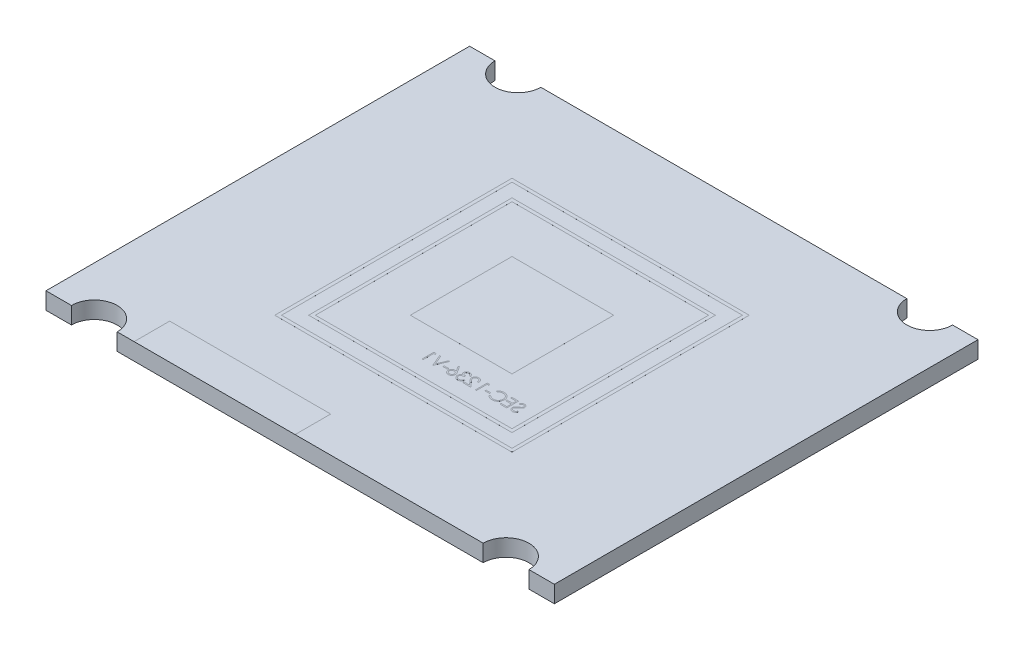
from build123d import *

# Parameters (mm, degrees)
SKETCH1_W               = 30
SKETCH1_H               = 25
BOSS_EXTRUDE1_DEPTH     = 0.5
SKETCH3_R               = 1.35
CUT_EXTRUDE2_DEPTH      = 1.5
CUT_EXTRUDE2_DEPTH_BACK = 1.5
SKETCH2_W               = 6
SKETCH2_H               = 6
BOSS_EXTRUDE2_DEPTH     = 0.50005
SKETCH4_R               = 2.25
BOSS_EXTRUDE3_DEPTH     = 2
SKETCH5_R               = 0.5
CUT_EXTRUDE3_DEPTH      = 0.4
REVOLVE1_ANGLE          = 180
CHAMFER1_SIZE           = 0.2
SKETCH9_W               = 9.5
SKETCH9_H               = 2.1
MARCA_O_FIOS_DEPTH      = 0.50005
SKETCH10_W              = 14
SKETCH10_H              = 14
SKETCH10_W_2            = 13.6
SKETCH10_H_2            = 13.6
SKETCH10_W_3            = 12
SKETCH10_H_3            = 12
SKETCH10_W_4            = 11.6
SKETCH10_H_4            = 11.6
CONTORNO_C_MERA_DEPTH   = 0.5005
SKETCH11_W              = 0.26923077
SKETCH11_H              = 0.071794871
BOSS_EXTRUDE6_DEPTH     = 0.5005


with BuildPart() as part:
    # Sketch1 → Boss-Extrude1 (new body, symmetric)
    with BuildSketch(Plane(origin=(0, 0, 0), x_dir=(1, 0, 0), z_dir=(0, 1, 0))):
        Rectangle(SKETCH1_W, SKETCH1_H)
    extrude(amount=BOSS_EXTRUDE1_DEPTH, both=True)

    # Sketch3 → Cut-Extrude2 (cut, two sides)
    with BuildSketch(Plane(origin=(0, 0, 0), x_dir=(1, 0, 0), z_dir=(0, 1, 0))) as cut_extrude2_sk:
        with Locations((-12.15, 12.5)):
            Circle(SKETCH3_R)
        with Locations((12.15, 12.5)):
            Circle(SKETCH3_R)
        with Locations((12.15, -12.5)):
            Circle(SKETCH3_R)
        with Locations((-12.15, -12.5)):
            Circle(SKETCH3_R)
    extrude(amount=CUT_EXTRUDE2_DEPTH, mode=Mode.SUBTRACT)
    extrude(cut_extrude2_sk.sketch, amount=-CUT_EXTRUDE2_DEPTH_BACK, mode=Mode.SUBTRACT)

    # Sketch2 → Boss-Extrude2 (add, symmetric)
    with BuildSketch(Plane(origin=(0, 0, 0), x_dir=(1, 0, 0), z_dir=(0, 1, 0))):
        Rectangle(SKETCH2_W, SKETCH2_H)
    extrude(amount=BOSS_EXTRUDE2_DEPTH, both=True)

    # Sketch4 → Boss-Extrude3 (add)
    with BuildSketch(Plane.XZ.offset(0.50005)):
        Circle(SKETCH4_R)
    extrude(amount=BOSS_EXTRUDE3_DEPTH)

    # Sketch5 → Cut-Extrude3 (cut)
    with BuildSketch(Plane.XZ.offset(2.50005)):
        Circle(SKETCH5_R)
    extrude(amount=-CUT_EXTRUDE3_DEPTH, mode=Mode.SUBTRACT)

    # Sketch6 → Revolve1 (revolve)
    with BuildSketch(Plane.XZ.offset(2.10005)):
        with BuildLine():
            Line((-0.5, 0), (0.5, 0))
            ThreePointArc((0.5, 0), (0, 0.5), (-0.5, 0))
        make_face()
    revolve(axis=Axis((-0.5, -2.10005, 0), (1, 0, 0)), revolution_arc=REVOLVE1_ANGLE)

    # Chamfer1
    chamfer1_edges = [part.edges().sort_by_distance(p)[0] for p in [
        (-2.25, -0.50005, 0),
        (-2.25, -2.50005, 0),
        (-0.5, -2.50005, 0),
    ]]
    chamfer(chamfer1_edges, length=CHAMFER1_SIZE)

    # Sketch9 → Marcação Fios (add, symmetric)
    with BuildSketch(Plane(origin=(0, 0, 0), x_dir=(1, 0, 0), z_dir=(0, 1, 0))):
        with Locations((-5.05, -11.45)):
            Rectangle(SKETCH9_W, SKETCH9_H)
    extrude(amount=MARCA_O_FIOS_DEPTH, both=True)

    # Sketch10 → Contorno Câmera (add, symmetric)
    with BuildSketch(Plane(origin=(0, 0, 0), x_dir=(1, 0, 0), z_dir=(0, 1, 0))):
        Rectangle(SKETCH10_W, SKETCH10_H)
        Rectangle(SKETCH10_W_2, SKETCH10_H_2, mode=Mode.SUBTRACT)
        Rectangle(SKETCH10_W_3, SKETCH10_H_3)
        Rectangle(SKETCH10_W_4, SKETCH10_H_4, mode=Mode.SUBTRACT)
    extrude(amount=CONTORNO_C_MERA_DEPTH, both=True)

    # Sketch11 → Boss-Extrude6 (add, symmetric)
    with BuildSketch(Plane(origin=(0, 0, 0), x_dir=(1, 0, 0), z_dir=(0, 1, 0))):
        with BuildLine():
            Line((5.140170855, -4.761384611), (5.080996176, -4.725907848))
            add(Edge.make_bspline(
                [(5.080996176, -4.725907848), (5.075492528, -4.735120725), (5.064947752, -4.752772242), (5.04735748, -4.77662385), (5.029130898, -4.796896281), (5.010133032, -4.813471603), (4.990479842, -4.82652138), (4.970043031, -4.835761827), (4.948891469, -4.841525022), (4.934496705, -4.842225039), (4.927310278, -4.842574515)],
                knots=[0, 0, 0, 0, 3.218e-05, 6.1656e-05, 8.8756e-05, 0.000113806, 0.000137103, 0.000159257, 0.000180854, 0.000202386, 0.000202386, 0.000202386, 0.000202386], degree=3))
            add(Edge.make_bspline(
                [(4.927310278, -4.842574515), (4.921172906, -4.84240358), (4.909005552, -4.842064702), (4.891093103, -4.838808542), (4.873696743, -4.833806116), (4.857175015, -4.82664193), (4.841755892, -4.817974233), (4.828234553, -4.807504997), (4.816545331, -4.795783756), (4.806983508, -4.782707225), (4.799647501, -4.768643795), (4.794009087, -4.754208605), (4.790880072, -4.739174891), (4.790408721, -4.729052799), (4.790170855, -4.723944707)],
                knots=[0, 0, 0, 0, 1.8396e-05, 3.6469e-05, 5.444e-05, 7.2595e-05, 9.037e-05, 0.000107367, 0.000123728, 0.000139883, 0.000155753, 0.000171197, 0.00018624, 0.000201566, 0.000201566, 0.000201566, 0.000201566], degree=3))
            add(Edge.make_bspline(
                [(4.790170855, -4.723944707), (4.790465718, -4.718116537), (4.791065129, -4.706268719), (4.796131425, -4.688788789), (4.804101275, -4.671490275), (4.811453803, -4.660790022), (4.815271016, -4.655234771)],
                knots=[0, 0, 0, 0, 1.7456e-05, 3.5486e-05, 5.4182e-05, 7.4369e-05, 7.4369e-05, 7.4369e-05, 7.4369e-05], degree=3))
            add(Edge.make_bspline(
                [(4.815271016, -4.655234771), (4.818405138, -4.651225407), (4.824984837, -4.642808247), (4.83629634, -4.6302792), (4.849569563, -4.617355516), (4.864350274, -4.603543705), (4.881176891, -4.589486145), (4.899522394, -4.57451249), (4.919855166, -4.559192174), (4.934115065, -4.548917661), (4.941472939, -4.543616182)],
                knots=[0, 0, 0, 0, 1.5264e-05, 3.2045e-05, 5.0587e-05, 7.0829e-05, 9.2716e-05, 0.000116346, 0.000141867, 0.000169074, 0.000169074, 0.000169074, 0.000169074], degree=3))
            add(Edge.make_bspline(
                [(4.941472939, -4.543616182), (4.948837738, -4.538370464), (4.962918673, -4.528341052), (4.98261039, -4.513456195), (5.000219282, -4.499847421), (5.015667086, -4.487386618), (5.028947005, -4.476072097), (5.040163687, -4.46601251), (5.049031399, -4.456935797), (5.053962515, -4.451047529), (5.056176464, -4.448403842)],
                knots=[0, 0, 0, 0, 2.7125e-05, 5.186e-05, 7.4047e-05, 9.3888e-05, 0.000111394, 0.000126382, 0.000139075, 0.000149418, 0.000149418, 0.000149418, 0.000149418], degree=3))
            add(Edge.make_bspline(
                [(5.056176464, -4.448403842), (5.059270973, -4.444283634), (5.065356741, -4.436180694), (5.073389942, -4.423515722), (5.080217774, -4.410551069), (5.085570241, -4.397251896), (5.090077485, -4.38380491), (5.093109071, -4.370034661), (5.09500735, -4.356002938), (5.095201747, -4.346560237), (5.095299061, -4.341833329)],
                knots=[0, 0, 0, 0, 1.5454e-05, 3.0392e-05, 4.4943e-05, 5.9343e-05, 7.3356e-05, 8.744e-05, 0.00010158, 0.000115754, 0.000115754, 0.000115754, 0.000115754], degree=3))
            add(Edge.make_bspline(
                [(5.095299061, -4.341833329), (5.095038019, -4.334427374), (5.094521515, -4.319773761), (5.090153411, -4.298367595), (5.083258833, -4.277930312), (5.073599855, -4.258664245), (5.061148384, -4.241071049), (5.046739189, -4.224948351), (5.029576892, -4.211394635), (5.010746368, -4.199552223), (4.990135093, -4.190283038), (4.968536912, -4.183290842), (4.945917498, -4.179328991), (4.930596871, -4.178760438), (4.922823099, -4.178471951)],
                knots=[0, 0, 0, 0, 2.22e-05, 4.3925e-05, 6.5254e-05, 8.6764e-05, 0.000108315, 0.000129755, 0.000151392, 0.000173688, 0.000196341, 0.000219002, 0.000241641, 0.00026496, 0.00026496, 0.00026496, 0.00026496], degree=3))
            add(Edge.make_bspline(
                [(4.922823099, -4.178471951), (4.914574279, -4.178756461), (4.898170009, -4.179322261), (4.874040165, -4.184241768), (4.850808022, -4.192381902), (4.832119369, -4.201619634), (4.817492817, -4.210845917), (4.80633827, -4.219249882), (4.79503478, -4.228924903), (4.783491169, -4.239896752), (4.771903037, -4.252266103), (4.760098347, -4.26594824), (4.748049493, -4.280859552), (4.740298321, -4.291504452), (4.736324702, -4.296961534)],
                knots=[0, 0, 0, 0, 2.4728e-05, 4.9175e-05, 7.3522e-05, 9.8418e-05, 0.000111528, 0.000125354, 0.000140274, 0.000156144, 0.000173106, 0.000191099, 0.000210349, 0.000230598, 0.000230598, 0.000230598, 0.000230598], degree=3))
            Line((4.736324702, -4.296961534), (4.793115567, -4.340010412))
            add(Edge.make_bspline(
                [(4.793115567, -4.340010412), (4.796544753, -4.335592674), (4.803148565, -4.327085144), (4.813174462, -4.31517088), (4.822624192, -4.304287585), (4.831934272, -4.294834559), (4.840612998, -4.286294132), (4.849036406, -4.278982181), (4.857083277, -4.272827062), (4.867226659, -4.26625835), (4.879970203, -4.259747049), (4.89596711, -4.254237233), (4.912684365, -4.250926221), (4.924070291, -4.250488444), (4.929834317, -4.250266823)],
                knots=[0, 0, 0, 0, 1.6775e-05, 3.2306e-05, 4.671e-05, 5.9999e-05, 7.2097e-05, 8.323e-05, 9.3439e-05, 0.000102462, 0.000119457, 0.00013622, 0.000153078, 0.000170362, 0.000170362, 0.000170362, 0.000170362], degree=3))
            add(Edge.make_bspline(
                [(4.929834317, -4.250266823), (4.937065621, -4.250509163), (4.951010511, -4.250976492), (4.970808558, -4.256080489), (4.988627343, -4.264116862), (5.003937856, -4.275379857), (5.016685252, -4.288724056), (5.025906343, -4.304079827), (5.031456376, -4.321036307), (5.032133632, -4.332864638), (5.032478548, -4.338888617)],
                knots=[0, 0, 0, 0, 2.165e-05, 4.1749e-05, 6.0886e-05, 7.9959e-05, 9.8411e-05, 0.000115894, 0.000133277, 0.000151318, 0.000151318, 0.000151318, 0.000151318], degree=3))
            add(Edge.make_bspline(
                [(5.032478548, -4.338888617), (5.032399922, -4.342638913), (5.032242543, -4.350145637), (5.030047584, -4.361235921), (5.027227718, -4.372298189), (5.022759191, -4.383282706), (5.016590131, -4.394381578), (5.008489096, -4.405785925), (4.998286433, -4.417596267), (4.990471031, -4.425277742), (4.986344734, -4.429333329)],
                knots=[0, 0, 0, 0, 1.1232e-05, 2.2482e-05, 3.3809e-05, 4.5449e-05, 5.7938e-05, 7.1827e-05, 8.734e-05, 0.000104693, 0.000104693, 0.000104693, 0.000104693], degree=3))
            add(Edge.make_bspline(
                [(4.986344734, -4.429333329), (4.984812459, -4.430700734), (4.981172126, -4.433949376), (4.974516941, -4.439267832), (4.965728381, -4.445828386), (4.955035941, -4.45394585), (4.942242468, -4.463362142), (4.927346557, -4.473956865), (4.910514251, -4.486073956), (4.898569867, -4.494545464), (4.892254189, -4.499024835)],
                knots=[0, 0, 0, 0, 6.16e-06, 1.4635e-05, 2.5545e-05, 3.9063e-05, 5.4909e-05, 7.3198e-05, 9.39e-05, 0.000117129, 0.000117129, 0.000117129, 0.000117129], degree=3))
            add(Edge.make_bspline(
                [(4.892254189, -4.499024835), (4.884657006, -4.504553107), (4.869946115, -4.51525784), (4.849014599, -4.531340976), (4.830035837, -4.547070529), (4.812943196, -4.562346051), (4.797567815, -4.577051669), (4.784080271, -4.591364305), (4.772343135, -4.60518142), (4.759707291, -4.622895935), (4.746795727, -4.644652152), (4.735707425, -4.6713078), (4.728715756, -4.698067064), (4.727801453, -4.716052431), (4.727350343, -4.724926278)],
                knots=[0, 0, 0, 0, 2.8186e-05, 5.4579e-05, 7.9176e-05, 0.000102117, 0.000123339, 0.000142981, 0.000161096, 0.000177674, 0.000208218, 0.000236759, 0.000264068, 0.000290665, 0.000290665, 0.000290665, 0.000290665], degree=3))
            add(Edge.make_bspline(
                [(4.727350343, -4.724926278), (4.72748177, -4.731201951), (4.727742073, -4.743631427), (4.730734256, -4.761882443), (4.735118189, -4.779608617), (4.741725636, -4.796590839), (4.749790267, -4.813139792), (4.760023517, -4.828821372), (4.771885054, -4.843982652), (4.785491807, -4.85821935), (4.800380987, -4.871288589), (4.816117726, -4.882914401), (4.832727781, -4.892608066), (4.850121044, -4.900518234), (4.868301512, -4.906704938), (4.887263068, -4.911187512), (4.907036971, -4.913938654), (4.920477067, -4.914224206), (4.927310278, -4.914369387)],
                knots=[0, 0, 0, 0, 1.8809e-05, 3.7253e-05, 5.5346e-05, 7.3498e-05, 9.1809e-05, 0.00011048, 0.000129555, 0.000149491, 0.000169462, 0.000188927, 0.000208094, 0.000227045, 0.000246158, 0.000265613, 0.000285424, 0.000305914, 0.000305914, 0.000305914, 0.000305914], degree=3))
            add(Edge.make_bspline(
                [(4.927310278, -4.914369387), (4.932597347, -4.91426715), (4.943104899, -4.914063965), (4.958646795, -4.912267709), (4.973874713, -4.909726288), (4.98859757, -4.905691474), (5.003005052, -4.900796079), (5.017034499, -4.894768413), (5.03069271, -4.887544972), (5.044056226, -4.879285967), (5.057091061, -4.869674418), (5.069674955, -4.858479719), (5.082220792, -4.846010618), (5.094358271, -4.831928505), (5.1063329, -4.816460889), (5.117908582, -4.799463052), (5.129324925, -4.781027581), (5.136488019, -4.768054564), (5.140170855, -4.761384611)],
                knots=[0, 0, 0, 0, 1.5855e-05, 3.1511e-05, 4.6888e-05, 6.2126e-05, 7.7247e-05, 9.2511e-05, 0.000107878, 0.00012356, 0.000139602, 0.000156394, 0.000174043, 0.00019263, 0.000212123, 0.000232698, 0.000254296, 0.00027715, 0.00027715, 0.00027715, 0.00027715], degree=3))
        make_face()
        Polygon((4.583760599, -4.196420669), (4.188888804, -4.196420669), (4.188888804, -4.268215541), (4.520940086, -4.268215541), (4.520940086, -4.483600156), (4.188888804, -4.483600156), (4.188888804, -4.555395028), (4.520940086, -4.555395028), (4.520940086, -4.824625797), (4.188888804, -4.824625797), (4.188888804, -4.896420669), (4.583760599, -4.896420669), align=None)
        with BuildLine():
            Line((3.417093932, -4.324866182), (3.472061881, -4.366933489))
            add(Edge.make_bspline(
                [(3.472061881, -4.366933489), (3.475983059, -4.362260295), (3.483772548, -4.352976912), (3.496304389, -4.339941003), (3.509364717, -4.327727951), (3.522948541, -4.316279575), (3.537300365, -4.305996222), (3.552072525, -4.296342001), (3.567512134, -4.287688454), (3.588862481, -4.277195856), (3.616792051, -4.266246625), (3.651951018, -4.257065979), (3.688653238, -4.251221744), (3.713692758, -4.250588776), (3.726428868, -4.250266823)],
                knots=[0, 0, 0, 0, 1.8297e-05, 3.6347e-05, 5.4205e-05, 7.1925e-05, 8.9596e-05, 0.000107137, 0.000124843, 0.000142654, 0.000178484, 0.000214606, 0.000251493, 0.000289678, 0.000289678, 0.000289678, 0.000289678], degree=3))
            add(Edge.make_bspline(
                [(3.726428868, -4.250266823), (3.733445528, -4.250347615), (3.747413727, -4.25050845), (3.768143421, -4.252630275), (3.788486032, -4.255612517), (3.808428325, -4.260037582), (3.827944916, -4.265632106), (3.847163397, -4.272317189), (3.865805517, -4.280588156), (3.884129164, -4.289729808), (3.901685007, -4.300055297), (3.918296016, -4.311317968), (3.93390161, -4.323391787), (3.948514132, -4.336322008), (3.962148522, -4.3500504), (3.974705984, -4.364723269), (3.986143066, -4.380293703), (3.996686471, -4.396556385), (4.006129018, -4.413463943), (4.014034994, -4.431078957), (4.021036018, -4.449099778), (4.026575867, -4.46773001), (4.03096077, -4.486838563), (4.033986303, -4.506476721), (4.036083997, -4.526603457), (4.036244032, -4.540245319), (4.036324702, -4.547121791)],
                knots=[0, 0, 0, 0, 2.1041e-05, 4.1887e-05, 6.2452e-05, 8.2696e-05, 0.000103113, 0.000123336, 0.000143683, 0.000164252, 0.000184742, 0.000204732, 0.000224422, 0.000243893, 0.000263228, 0.000282422, 0.000301774, 0.000321144, 0.000340538, 0.000359803, 0.000379021, 0.000398496, 0.000418056, 0.00043779, 0.000458077, 0.000478698, 0.000478698, 0.000478698, 0.000478698], degree=3))
            add(Edge.make_bspline(
                [(4.036324702, -4.547121791), (4.036072338, -4.557468054), (4.035576855, -4.577781571), (4.031167188, -4.607535694), (4.02446617, -4.636039828), (4.014423054, -4.663115797), (4.002039244, -4.689097468), (3.986391122, -4.713545239), (3.968267815, -4.736828552), (3.947412931, -4.758397142), (3.924531767, -4.778099887), (3.899982185, -4.795450003), (3.873825328, -4.809912979), (3.846350002, -4.821948169), (3.817344779, -4.831199514), (3.786861818, -4.837712339), (3.754967419, -4.841960775), (3.733173539, -4.842367513), (3.722081913, -4.842574515)],
                knots=[0, 0, 0, 0, 3.1021e-05, 6.0906e-05, 9.0053e-05, 0.00011871, 0.000147371, 0.000176236, 0.000205605, 0.000235754, 0.000266082, 0.000296076, 0.000325767, 0.000355596, 0.000385928, 0.000416925, 0.000449015, 0.000482272, 0.000482272, 0.000482272, 0.000482272], degree=3))
            add(Edge.make_bspline(
                [(3.722081913, -4.842574515), (3.709861375, -4.842236759), (3.685808433, -4.841571974), (3.650534828, -4.835940125), (3.616767675, -4.826808541), (3.584505158, -4.814028957), (3.553838229, -4.797415899), (3.524718896, -4.777276323), (3.497122582, -4.753418657), (3.480528326, -4.735202031), (3.472061881, -4.725907848)],
                knots=[0, 0, 0, 0, 3.6644e-05, 7.2124e-05, 0.000106855, 0.000141409, 0.000175979, 0.000211258, 0.000247442, 0.000285133, 0.000285133, 0.000285133, 0.000285133], degree=3))
            Line((3.472061881, -4.725907848), (3.417093932, -4.767554483))
            add(Edge.make_bspline(
                [(3.417093932, -4.767554483), (3.421517554, -4.773262173), (3.430343609, -4.784650214), (3.444635213, -4.800704556), (3.459690672, -4.815805363), (3.475621814, -4.829830888), (3.492245373, -4.843061781), (3.509859835, -4.855122147), (3.528233641, -4.866180324), (3.547304537, -4.876305709), (3.56705226, -4.885289158), (3.587453147, -4.892979912), (3.608419262, -4.89960489), (3.629951564, -4.905055277), (3.652094715, -4.909309494), (3.67476881, -4.912153429), (3.698022785, -4.914101812), (3.713711069, -4.914279395), (3.72166124, -4.914369387)],
                knots=[0, 0, 0, 0, 2.1659e-05, 4.3214e-05, 6.4432e-05, 8.5591e-05, 0.000106856, 0.000128132, 0.000149583, 0.000171161, 0.000192874, 0.00021462, 0.000236529, 0.000258805, 0.000281218, 0.000304125, 0.000327333, 0.000351178, 0.000351178, 0.000351178, 0.000351178], degree=3))
            add(Edge.make_bspline(
                [(3.72166124, -4.914369387), (3.729189973, -4.914316988), (3.744077111, -4.914213377), (3.766056862, -4.912534943), (3.787454778, -4.910244996), (3.808209703, -4.906796969), (3.828434898, -4.902728101), (3.847947015, -4.89727385), (3.866938057, -4.891164017), (3.885331725, -4.883983019), (3.903143665, -4.875879783), (3.920316427, -4.866721471), (3.936842114, -4.856585098), (3.952883198, -4.845694096), (3.968202715, -4.833698636), (3.98293342, -4.820765309), (3.997157915, -4.806937707), (4.005958452, -4.796966736), (4.010383195, -4.791953521)],
                knots=[0, 0, 0, 0, 2.258e-05, 4.4649e-05, 6.6096e-05, 8.7121e-05, 0.000107746, 0.000127953, 0.000147863, 0.000167576, 0.000187153, 0.000206537, 0.000225921, 0.00024529, 0.000264672, 0.000284248, 0.00030408, 0.000324133, 0.000324133, 0.000324133, 0.000324133], degree=3))
            add(Edge.make_bspline(
                [(4.010383195, -4.791953521), (4.017470324, -4.783245283), (4.031559019, -4.765933941), (4.049584156, -4.737876745), (4.065013667, -4.708583103), (4.077488851, -4.677899118), (4.087241398, -4.64589364), (4.093997637, -4.612550537), (4.098387958, -4.577900949), (4.098890015, -4.554333591), (4.099145214, -4.542354162)],
                knots=[0, 0, 0, 0, 3.3661e-05, 6.6916e-05, 9.9845e-05, 0.000132863, 0.000166132, 0.000200068, 0.000234819, 0.000270744, 0.000270744, 0.000270744, 0.000270744], degree=3))
            add(Edge.make_bspline(
                [(4.099145214, -4.542354162), (4.098834176, -4.529763072), (4.098222226, -4.504990887), (4.093023067, -4.468636096), (4.084659308, -4.433805816), (4.07277993, -4.400565067), (4.05771886, -4.368739011), (4.039113537, -4.33857077), (4.017180109, -4.30986741), (3.992090595, -4.28306446), (3.964577128, -4.25855659), (3.935113365, -4.236995349), (3.903756976, -4.219051846), (3.870853406, -4.204052613), (3.836156269, -4.192523721), (3.799739596, -4.184453083), (3.761671813, -4.17942966), (3.735699328, -4.178794618), (3.722502586, -4.178471951)],
                knots=[0, 0, 0, 0, 3.7758e-05, 7.4286e-05, 0.000109929, 0.000145056, 0.000179992, 0.000215369, 0.000251183, 0.00028819, 0.000325338, 0.000361576, 0.000397509, 0.000433531, 0.000469892, 0.000506973, 0.00054529, 0.000584869, 0.000584869, 0.000584869, 0.000584869], degree=3))
            add(Edge.make_bspline(
                [(3.722502586, -4.178471951), (3.714459692, -4.178568378), (3.698539592, -4.178759247), (3.674989062, -4.180620476), (3.652060596, -4.183723197), (3.6297384, -4.187946411), (3.607913877, -4.193187875), (3.586753829, -4.200015935), (3.566134091, -4.207823241), (3.54618471, -4.216814934), (3.5270014, -4.226908283), (3.508590136, -4.237991407), (3.491097164, -4.250050568), (3.474399394, -4.262983203), (3.458776152, -4.277062915), (3.443783857, -4.291902434), (3.429931641, -4.307929199), (3.421381002, -4.319210186), (3.417093932, -4.324866182)],
                knots=[0, 0, 0, 0, 2.4125e-05, 4.7753e-05, 7.0817e-05, 9.3506e-05, 0.000115885, 0.000138102, 0.000160161, 0.000182001, 0.000203704, 0.000225155, 0.00024643, 0.000267412, 0.000288466, 0.000309486, 0.000330658, 0.000351947, 0.000351947, 0.000351947, 0.000351947], degree=3))
        make_face()
        with Locations((3.201709317, -4.6271899)):
            Rectangle(SKETCH11_W, SKETCH11_H)
        Polygon((2.864469734, -4.196420669), (2.73504265, -4.196420669), (2.73504265, -4.896420669), (2.797863163, -4.896420669), (2.797863163, -4.268215541), (2.905555471, -4.268215541), align=None)
        with BuildLine():
            Line((2.38504265, -4.411805284), (2.447863163, -4.411805284))
            add(Edge.make_bspline(
                [(2.447863163, -4.411805284), (2.447453732, -4.403471107), (2.446649622, -4.387103004), (2.442883964, -4.363238222), (2.437495788, -4.340427263), (2.429877498, -4.31885328), (2.420416242, -4.298325518), (2.409070237, -4.278925515), (2.395631466, -4.260727277), (2.38039012, -4.243899509), (2.363836392, -4.228461995), (2.345975204, -4.215130946), (2.327206198, -4.203867412), (2.307586319, -4.194451163), (2.286894206, -4.187383194), (2.265317634, -4.182138866), (2.242761807, -4.178983597), (2.227393803, -4.17864444), (2.219577907, -4.178471951)],
                knots=[0, 0, 0, 0, 2.5017e-05, 4.9132e-05, 7.2361e-05, 9.5245e-05, 0.000117643, 0.000140081, 0.000162546, 0.000185382, 0.000208106, 0.000230345, 0.000252109, 0.000273686, 0.000295504, 0.000317577, 0.000340224, 0.000363662, 0.000363662, 0.000363662, 0.000363662], degree=3))
            add(Edge.make_bspline(
                [(2.219577907, -4.178471951), (2.211902292, -4.178651642), (2.196819983, -4.179004729), (2.17480758, -4.182036935), (2.153852121, -4.186786053), (2.133994568, -4.193449136), (2.115393355, -4.202406022), (2.097908746, -4.21316553), (2.081332584, -4.225609496), (2.066411227, -4.240260259), (2.052709611, -4.255900736), (2.04088916, -4.272598316), (2.030766528, -4.289844173), (2.022328992, -4.307769814), (2.016117764, -4.326544019), (2.011402122, -4.34589346), (2.008736639, -4.366018422), (2.008327555, -4.379639733), (2.008119573, -4.386564899)],
                knots=[0, 0, 0, 0, 2.3018e-05, 4.5229e-05, 6.6523e-05, 8.7409e-05, 0.000107918, 0.000128312, 0.000148926, 0.00016995, 0.000190924, 0.000211235, 0.00023122, 0.000250857, 0.000270545, 0.000290442, 0.000310531, 0.000331307, 0.000331307, 0.000331307, 0.000331307], degree=3))
            add(Edge.make_bspline(
                [(2.008119573, -4.386564899), (2.008458226, -4.396314466), (2.009129588, -4.415642509), (2.014872463, -4.444045482), (2.023841766, -4.471564165), (2.034641237, -4.493711626), (2.045535726, -4.511558325), (2.055353227, -4.526252066), (2.06684619, -4.542073159), (2.080181889, -4.558968627), (2.095084464, -4.577070808), (2.111688896, -4.596368767), (2.130113593, -4.616663121), (2.143045293, -4.630524241), (2.149746176, -4.637706726)],
                knots=[0, 0, 0, 0, 2.9224e-05, 5.7934e-05, 8.658e-05, 0.000115868, 0.000131596, 0.000149291, 0.000168869, 0.000190244, 0.000213854, 0.000239208, 0.000266609, 0.000296078, 0.000296078, 0.000296078, 0.000296078], degree=3))
            Line((2.149746176, -4.637706726), (2.3248864, -4.824625797))
            Line((2.3248864, -4.824625797), (1.999145214, -4.824625797))
            Line((1.999145214, -4.824625797), (1.999145214, -4.896420669))
            Line((1.999145214, -4.896420669), (2.47478624, -4.896420669))
            Line((2.47478624, -4.896420669), (2.203311881, -4.606717143))
            add(Edge.make_bspline(
                [(2.203311881, -4.606717143), (2.196702304, -4.599817482), (2.184006658, -4.586564644), (2.166050143, -4.567216052), (2.149922345, -4.549266144), (2.135518867, -4.532748835), (2.123152166, -4.517422521), (2.112177719, -4.50378358), (2.103384601, -4.49123269), (2.093841522, -4.476684567), (2.084598726, -4.458922104), (2.076656254, -4.437215366), (2.071813285, -4.414869916), (2.071232318, -4.399769508), (2.070940086, -4.392173874)],
                knots=[0, 0, 0, 0, 2.8664e-05, 5.5057e-05, 7.9186e-05, 0.000101057, 0.00012079, 0.000138266, 0.000153556, 0.000166742, 0.000190449, 0.000213427, 0.000235924, 0.000258692, 0.000258692, 0.000258692, 0.000258692], degree=3))
            add(Edge.make_bspline(
                [(2.070940086, -4.392173874), (2.071067235, -4.387397594), (2.07131782, -4.377984464), (2.073529359, -4.364183312), (2.076871461, -4.35087035), (2.081660512, -4.338004626), (2.08798186, -4.325715495), (2.095676536, -4.313987999), (2.104554549, -4.302650206), (2.114824803, -4.292019547), (2.126107107, -4.282283305), (2.138025957, -4.273658488), (2.150635977, -4.266450666), (2.163884002, -4.260541967), (2.177733096, -4.255906891), (2.192210045, -4.252695175), (2.207274848, -4.250678678), (2.217561547, -4.250405844), (2.222803067, -4.250266823)],
                knots=[0, 0, 0, 0, 1.432e-05, 2.8222e-05, 4.1826e-05, 5.5448e-05, 6.9308e-05, 8.3193e-05, 9.7471e-05, 0.000112447, 0.000127458, 0.000142129, 0.000156513, 0.00017095, 0.000185583, 0.000200245, 0.000215377, 0.000231098, 0.000231098, 0.000231098, 0.000231098], degree=3))
            add(Edge.make_bspline(
                [(2.222803067, -4.250266823), (2.228277233, -4.250409829), (2.239027593, -4.25069067), (2.254811399, -4.252655203), (2.269868555, -4.256044371), (2.284236935, -4.260679706), (2.297940853, -4.266571416), (2.310913661, -4.273909765), (2.323126239, -4.282666463), (2.334601544, -4.292594574), (2.34517434, -4.303648095), (2.354463715, -4.315970087), (2.362580518, -4.32933557), (2.369662364, -4.34370848), (2.375413502, -4.359219236), (2.379808132, -4.375812777), (2.383285502, -4.393417054), (2.384447206, -4.405574071), (2.38504265, -4.411805284)],
                knots=[0, 0, 0, 0, 1.6421e-05, 3.2249e-05, 4.7625e-05, 6.2658e-05, 7.748e-05, 9.2299e-05, 0.000107279, 0.000122489, 0.000137764, 0.000153077, 0.000168684, 0.000184613, 0.000201075, 0.000218219, 0.000236067, 0.000254835, 0.000254835, 0.000254835, 0.000254835], degree=3))
        make_face()
        with BuildLine():
            Line((1.846581112, -4.35795913), (1.909401625, -4.35795913))
            add(Edge.make_bspline(
                [(1.909401625, -4.35795913), (1.907699714, -4.350912633), (1.904372619, -4.337137309), (1.897433105, -4.317455856), (1.889873254, -4.298831152), (1.880795433, -4.281611937), (1.870893682, -4.265452157), (1.859549138, -4.250718332), (1.847285193, -4.237035739), (1.833720203, -4.224893091), (1.819494471, -4.213897545), (1.804407547, -4.204522534), (1.788762968, -4.196457703), (1.772452342, -4.189813657), (1.755427107, -4.184808552), (1.737841183, -4.181177191), (1.719648483, -4.178818968), (1.707298964, -4.178588816), (1.701028227, -4.178471951)],
                knots=[0, 0, 0, 0, 2.1733e-05, 4.2486e-05, 6.2538e-05, 8.1981e-05, 0.000100813, 0.000119324, 0.000137689, 0.000155856, 0.000173861, 0.000191564, 0.000209061, 0.000226612, 0.000244314, 0.000262217, 0.000280445, 0.000299248, 0.000299248, 0.000299248, 0.000299248], degree=3))
            add(Edge.make_bspline(
                [(1.701028227, -4.178471951), (1.691891679, -4.178747797), (1.673817877, -4.179293472), (1.647265267, -4.184276359), (1.621659903, -4.192161386), (1.597282054, -4.203056131), (1.574638367, -4.216493594), (1.55449113, -4.232486541), (1.537113428, -4.250726401), (1.522534552, -4.270872914), (1.511119552, -4.292404016), (1.502702278, -4.314564048), (1.497577942, -4.337300442), (1.49691383, -4.352651898), (1.496581112, -4.360342944)],
                knots=[0, 0, 0, 0, 2.7387e-05, 5.4177e-05, 8.0745e-05, 0.000107611, 0.000134088, 0.000159535, 0.000184529, 0.000209437, 0.000233902, 0.000257421, 0.000280387, 0.000303445, 0.000303445, 0.000303445, 0.000303445], degree=3))
            add(Edge.make_bspline(
                [(1.496581112, -4.360342944), (1.49681383, -4.367744303), (1.497269223, -4.382227614), (1.501135965, -4.403371914), (1.507643217, -4.423300234), (1.51665717, -4.442096466), (1.52832548, -4.459641434), (1.542460019, -4.475974612), (1.559160551, -4.491168444), (1.571816339, -4.499872338), (1.578331913, -4.504353361)],
                knots=[0, 0, 0, 0, 2.2191e-05, 4.3425e-05, 6.4222e-05, 8.4919e-05, 0.000105765, 0.000127241, 0.000149577, 0.000173279, 0.000173279, 0.000173279, 0.000173279], degree=3))
            add(Edge.make_bspline(
                [(1.578331913, -4.504353361), (1.570885562, -4.507948995), (1.556132187, -4.515072987), (1.536022081, -4.529044138), (1.517766506, -4.545175408), (1.507585763, -4.557763938), (1.502470535, -4.564088938)],
                knots=[0, 0, 0, 0, 2.4773e-05, 4.9082e-05, 7.321e-05, 9.7576e-05, 9.7576e-05, 9.7576e-05, 9.7576e-05], degree=3))
            add(Edge.make_bspline(
                [(1.502470535, -4.564088938), (1.499102266, -4.568700488), (1.492420887, -4.577848072), (1.48417378, -4.592555357), (1.476691958, -4.607425655), (1.470861914, -4.622857536), (1.46634714, -4.638672139), (1.463119934, -4.654896618), (1.461115106, -4.671544222), (1.460827995, -4.682806718), (1.460683676, -4.688467944)],
                knots=[0, 0, 0, 0, 1.7117e-05, 3.3953e-05, 5.0509e-05, 6.702e-05, 8.3353e-05, 9.9798e-05, 0.0001166, 0.000133582, 0.000133582, 0.000133582, 0.000133582], degree=3))
            add(Edge.make_bspline(
                [(1.460683676, -4.688467944), (1.461042579, -4.698269889), (1.461758695, -4.717827649), (1.46815951, -4.746722593), (1.478082158, -4.774967694), (1.492173545, -4.801982662), (1.509347047, -4.827258738), (1.529778512, -4.849874), (1.553235793, -4.86931372), (1.579396923, -4.885555766), (1.607740349, -4.898539351), (1.638055467, -4.907550839), (1.669905478, -4.913420039), (1.691746938, -4.914049413), (1.702851144, -4.914369387)],
                knots=[0, 0, 0, 0, 2.9373e-05, 5.8607e-05, 8.8367e-05, 0.000118971, 0.000149737, 0.000179817, 0.000210087, 0.000240826, 0.00027195, 0.000303312, 0.000335495, 0.000368779, 0.000368779, 0.000368779, 0.000368779], degree=3))
            add(Edge.make_bspline(
                [(1.702851144, -4.914369387), (1.710335004, -4.914195744), (1.725060745, -4.913854073), (1.746709445, -4.911518353), (1.767373784, -4.907252352), (1.787081704, -4.901511691), (1.805850711, -4.894233342), (1.823623532, -4.885169603), (1.840509511, -4.874507302), (1.856349301, -4.862120585), (1.871141015, -4.848264317), (1.88449156, -4.832692515), (1.896623518, -4.815693034), (1.907212046, -4.797068423), (1.916739437, -4.777059371), (1.924575628, -4.755409672), (1.931472742, -4.732312867), (1.934679434, -4.716217319), (1.936324702, -4.70795913)],
                knots=[0, 0, 0, 0, 2.2452e-05, 4.4177e-05, 6.5215e-05, 8.5671e-05, 0.000105696, 0.000125513, 0.00014543, 0.000165514, 0.00018575, 0.000206131, 0.000226947, 0.000248305, 0.000270322, 0.000293349, 0.00031731, 0.000342558, 0.000342558, 0.000342558, 0.000342558], degree=3))
            Line((1.936324702, -4.70795913), (1.873504189, -4.70795913))
            add(Edge.make_bspline(
                [(1.873504189, -4.70795913), (1.87186753, -4.713348933), (1.868684088, -4.723832567), (1.863265228, -4.738920628), (1.857091574, -4.752752239), (1.850468662, -4.765428863), (1.843512973, -4.777075344), (1.835729988, -4.787383718), (1.827696159, -4.796806758), (1.821640288, -4.802115681), (1.818676464, -4.804713938)],
                knots=[0, 0, 0, 0, 1.6897e-05, 3.2867e-05, 4.8059e-05, 6.2296e-05, 7.5763e-05, 8.8692e-05, 0.000101013, 0.000112823, 0.000112823, 0.000112823, 0.000112823], degree=3))
            add(Edge.make_bspline(
                [(1.818676464, -4.804713938), (1.814757149, -4.807735605), (1.806930616, -4.813769611), (1.79417697, -4.821469937), (1.780763993, -4.828142142), (1.766401058, -4.833238881), (1.751398104, -4.837554413), (1.735512631, -4.840378517), (1.718884788, -4.842316151), (1.707531235, -4.842487138), (1.701729349, -4.842574515)],
                knots=[0, 0, 0, 0, 1.4836e-05, 2.9626e-05, 4.4614e-05, 5.9698e-05, 7.528e-05, 9.1397e-05, 0.000108043, 0.00012544, 0.00012544, 0.00012544, 0.00012544], degree=3))
            add(Edge.make_bspline(
                [(1.701729349, -4.842574515), (1.695178648, -4.842451334), (1.682369319, -4.842210464), (1.663678347, -4.839995323), (1.645896858, -4.83676924), (1.629222273, -4.831786643), (1.613436171, -4.825630473), (1.598759841, -4.817900792), (1.58500062, -4.808831848), (1.572334739, -4.798524016), (1.560945637, -4.787239717), (1.550917735, -4.775437103), (1.542392802, -4.763165937), (1.535516087, -4.750358313), (1.530085977, -4.737067267), (1.526389337, -4.723255501), (1.523819034, -4.709036048), (1.523609711, -4.699370254), (1.523504189, -4.694497592)],
                knots=[0, 0, 0, 0, 1.9644e-05, 3.8412e-05, 5.6398e-05, 7.3791e-05, 9.0535e-05, 0.000107156, 0.000123451, 0.000139898, 0.000156061, 0.000171483, 0.000186303, 0.000200796, 0.000215013, 0.000229267, 0.000243629, 0.000258229, 0.000258229, 0.000258229, 0.000258229], degree=3))
            add(Edge.make_bspline(
                [(1.523504189, -4.694497592), (1.523810249, -4.687975324), (1.524420847, -4.674963242), (1.529082563, -4.655819728), (1.536750335, -4.637375045), (1.547484838, -4.619943887), (1.560551983, -4.603788707), (1.575824965, -4.58937441), (1.59343061, -4.577480392), (1.609634584, -4.569262661), (1.623987616, -4.563655246), (1.636270692, -4.559920253), (1.650022013, -4.556757522), (1.665075283, -4.553815067), (1.681543926, -4.551310798), (1.699410014, -4.549222435), (1.718677166, -4.547551426), (1.732015399, -4.546805207), (1.738888804, -4.546420669)],
                knots=[0, 0, 0, 0, 1.9552e-05, 3.9007e-05, 5.8746e-05, 7.926e-05, 0.000100196, 0.000120931, 0.000142012, 0.00016371, 0.000175297, 0.000188205, 0.000202184, 0.000217612, 0.000234211, 0.000252143, 0.000271567, 0.000292219, 0.000292219, 0.000292219, 0.000292219], degree=3))
            Line((1.738888804, -4.546420669), (1.738888804, -4.474625797))
            add(Edge.make_bspline(
                [(1.738888804, -4.474625797), (1.730228571, -4.474478836), (1.713265302, -4.474190976), (1.688486441, -4.470709374), (1.664791778, -4.465893248), (1.64270643, -4.45851621), (1.622576687, -4.449948151), (1.605112767, -4.439977709), (1.590559337, -4.428894759), (1.578987123, -4.416528237), (1.570281277, -4.403265228), (1.563915918, -4.389441896), (1.560155853, -4.374937084), (1.559653919, -4.36503815), (1.559401625, -4.360062496)],
                knots=[0, 0, 0, 0, 2.596e-05, 5.0849e-05, 7.4942e-05, 9.84e-05, 0.000120568, 0.000140483, 0.000158574, 0.000175243, 0.000191033, 0.000205968, 0.000220729, 0.000235646, 0.000235646, 0.000235646, 0.000235646], degree=3))
            add(Edge.make_bspline(
                [(1.559401625, -4.360062496), (1.559484507, -4.356406947), (1.559649397, -4.349134405), (1.561728853, -4.338509391), (1.564853661, -4.328209202), (1.569149607, -4.31827764), (1.574899646, -4.308783585), (1.581780844, -4.299646096), (1.589974464, -4.29091734), (1.599363553, -4.282781276), (1.609445914, -4.275027428), (1.620495869, -4.268444701), (1.632180244, -4.262815689), (1.644511975, -4.258173788), (1.657531081, -4.254681931), (1.671176393, -4.252174762), (1.685473929, -4.250607231), (1.695228276, -4.250381548), (1.700186881, -4.250266823)],
                knots=[0, 0, 0, 0, 1.0952e-05, 2.1788e-05, 3.2345e-05, 4.3209e-05, 5.4151e-05, 6.5565e-05, 7.747e-05, 8.9989e-05, 0.000102805, 0.000115575, 0.000128494, 0.000141673, 0.000155042, 0.000168876, 0.000183262, 0.000198136, 0.000198136, 0.000198136, 0.000198136], degree=3))
            add(Edge.make_bspline(
                [(1.700186881, -4.250266823), (1.708157215, -4.250545095), (1.72372513, -4.251088626), (1.746168113, -4.255849228), (1.76703198, -4.263444845), (1.782979713, -4.272511449), (1.794756228, -4.281461536), (1.803171616, -4.289278013), (1.811435718, -4.297964578), (1.819004853, -4.308056253), (1.826659649, -4.318869611), (1.833628561, -4.330954347), (1.840400499, -4.343995226), (1.844481009, -4.353214353), (1.846581112, -4.35795913)],
                knots=[0, 0, 0, 0, 2.3888e-05, 4.6659e-05, 6.8487e-05, 9.028e-05, 0.000101386, 0.0001128, 0.000124705, 0.000137298, 0.000150601, 0.000164429, 0.000179105, 0.000194667, 0.000194667, 0.000194667, 0.000194667], degree=3))
        make_face()
        with BuildLine():
            Line((1.07478624, -4.178471951), (1.026408836, -4.216472752))
            Line((1.026408836, -4.216472752), (1.211364766, -4.499305284))
            add(Edge.make_bspline(
                [(1.211364766, -4.499305284), (1.19905071, -4.497342512), (1.175030753, -4.493513903), (1.150717573, -4.492882314), (1.138868772, -4.492574515)],
                knots=[0, 0, 0, 0, 3.7362e-05, 7.2878e-05, 7.2878e-05, 7.2878e-05, 7.2878e-05], degree=3))
            add(Edge.make_bspline(
                [(1.138868772, -4.492574515), (1.131754273, -4.492765737), (1.117749593, -4.493142153), (1.097188232, -4.496038923), (1.077430445, -4.500603945), (1.058558123, -4.507258396), (1.040503526, -4.515758867), (1.023163047, -4.525946641), (1.006862645, -4.538347777), (0.991392409, -4.552200769), (0.97734699, -4.567544165), (0.964911779, -4.583824433), (0.95446642, -4.601024609), (0.945991636, -4.619135982), (0.93941066, -4.638130634), (0.934613131, -4.657984262), (0.931777213, -4.678710556), (0.931392114, -4.692806191), (0.931196496, -4.699966342)],
                knots=[0, 0, 0, 0, 2.1337e-05, 4.2001e-05, 6.217e-05, 8.2082e-05, 0.000101905, 0.000121962, 0.000142294, 0.000163244, 0.000184184, 0.000204601, 0.00022461, 0.000244433, 0.000264477, 0.000284816, 0.000305619, 0.000327095, 0.000327095, 0.000327095, 0.000327095], degree=3))
            add(Edge.make_bspline(
                [(0.931196496, -4.699966342), (0.931481117, -4.709762283), (0.932041184, -4.729038376), (0.937621943, -4.757113717), (0.946293872, -4.78386022), (0.958689378, -4.808850854), (0.974085855, -4.832051368), (0.992861373, -4.852608461), (1.014350071, -4.870942469), (1.03864743, -4.886273793), (1.064796023, -4.898794403), (1.092266423, -4.907787451), (1.120791852, -4.913324145), (1.140152774, -4.914018266), (1.149946496, -4.914369387)],
                knots=[0, 0, 0, 0, 2.9355e-05, 5.7764e-05, 8.5523e-05, 0.000113492, 0.000141183, 0.000168782, 0.000196738, 0.000225679, 0.000254719, 0.000283498, 0.000312182, 0.000341546, 0.000341546, 0.000341546, 0.000341546], degree=3))
            add(Edge.make_bspline(
                [(1.149946496, -4.914369387), (1.159365837, -4.914063746), (1.1780239, -4.913458324), (1.205470459, -4.908065136), (1.231843062, -4.899323716), (1.256956939, -4.88728086), (1.280221061, -4.872069283), (1.301034189, -4.853756828), (1.319292543, -4.832734935), (1.334487468, -4.809006865), (1.346539214, -4.783508874), (1.355577199, -4.756921442), (1.360856448, -4.729341446), (1.361594159, -4.710645218), (1.361965727, -4.701228361)],
                knots=[0, 0, 0, 0, 2.8235e-05, 5.5929e-05, 8.3555e-05, 0.000111402, 0.000139248, 0.000166673, 0.000194309, 0.000222508, 0.000250922, 0.000278725, 0.000306556, 0.0003348, 0.0003348, 0.0003348, 0.0003348], degree=3))
            add(Edge.make_bspline(
                [(1.361965727, -4.701228361), (1.361729438, -4.694019444), (1.361246981, -4.679300214), (1.357878303, -4.657007408), (1.352465344, -4.634197192), (1.346403295, -4.614846353), (1.339998173, -4.598994049), (1.334667665, -4.586213351), (1.328032866, -4.573061136), (1.32095819, -4.559086409), (1.312806816, -4.544649322), (1.303943686, -4.529508589), (1.294123756, -4.513905003), (1.287239723, -4.503316164), (1.283720535, -4.497903041)],
                knots=[0, 0, 0, 0, 2.1624e-05, 4.4151e-05, 6.7484e-05, 9.1919e-05, 0.000104887, 0.00011877, 0.000133444, 0.00014906, 0.000165758, 0.00018317, 0.00020169, 0.00022106, 0.00022106, 0.00022106, 0.00022106], degree=3))
            Line((1.283720535, -4.497903041), (1.07478624, -4.178471951))
        make_face()
        with BuildLine():
            add(Edge.make_bspline(
                [(1.152049862, -4.564369387), (1.157382311, -4.564524995), (1.167798133, -4.564828944), (1.183079616, -4.566593995), (1.197542266, -4.569917808), (1.211377693, -4.574151074), (1.224327233, -4.579971686), (1.236485001, -4.587042046), (1.247898012, -4.595366282), (1.258446722, -4.604826464), (1.268010655, -4.615184071), (1.276246881, -4.626277975), (1.283351361, -4.637840816), (1.289127724, -4.649969204), (1.29362574, -4.662658504), (1.29687939, -4.675850354), (1.29869014, -4.689633215), (1.298991386, -4.698979716), (1.299145214, -4.703752399)],
                knots=[0, 0, 0, 0, 1.6001e-05, 3.1254e-05, 4.6053e-05, 6.0466e-05, 7.459e-05, 8.854e-05, 0.000102591, 0.000116891, 0.000130984, 0.00014481, 0.000158277, 0.000171637, 0.000185031, 0.000198601, 0.000212325, 0.000226645, 0.000226645, 0.000226645, 0.000226645], degree=3))
            add(Edge.make_bspline(
                [(1.299145214, -4.703752399), (1.299019942, -4.708482395), (1.298774302, -4.717757213), (1.296543838, -4.731425049), (1.293136821, -4.744578031), (1.288068742, -4.757148351), (1.282023364, -4.769327614), (1.2740423, -4.780674671), (1.265198942, -4.791878685), (1.254628156, -4.80207898), (1.243283483, -4.811570305), (1.231163243, -4.819866355), (1.218531251, -4.82696359), (1.205216966, -4.832525809), (1.19140929, -4.837090667), (1.176993179, -4.840302963), (1.161958608, -4.842119068), (1.15177422, -4.842420707), (1.146581112, -4.842574515)],
                knots=[0, 0, 0, 0, 1.418e-05, 2.7805e-05, 4.1444e-05, 5.4854e-05, 6.84e-05, 8.213e-05, 9.6386e-05, 0.000111161, 0.000126098, 0.000140723, 0.00015516, 0.000169484, 0.000183941, 0.000198739, 0.000213714, 0.000229295, 0.000229295, 0.000229295, 0.000229295], degree=3))
            add(Edge.make_bspline(
                [(1.146581112, -4.842574515), (1.141388012, -4.842420695), (1.131203641, -4.842119032), (1.116168949, -4.840303098), (1.101753285, -4.837090169), (1.087943984, -4.832527615), (1.074635697, -4.826956893), (1.062014753, -4.819910509), (1.050009134, -4.811519285), (1.038657015, -4.8020952), (1.028130227, -4.791820629), (1.019074771, -4.780774685), (1.011338124, -4.769235906), (1.005051287, -4.757196328), (1.000039029, -4.74457043), (0.996614735, -4.731427086), (0.994388878, -4.71775668), (0.994142604, -4.708482215), (0.994017009, -4.703752399)],
                knots=[0, 0, 0, 0, 1.5581e-05, 3.0556e-05, 4.5355e-05, 5.9811e-05, 7.4136e-05, 8.8573e-05, 0.000103082, 0.000118019, 0.000132793, 0.000147139, 0.00016079, 0.0001744, 0.00018781, 0.00020145, 0.000215075, 0.000229255, 0.000229255, 0.000229255, 0.000229255], degree=3))
            add(Edge.make_bspline(
                [(0.994017009, -4.703752399), (0.994127068, -4.698973489), (0.994343077, -4.689594043), (0.996786267, -4.675856519), (1.000174742, -4.662591478), (1.005291348, -4.649882288), (1.011938657, -4.637779103), (1.020035338, -4.626220782), (1.029401852, -4.615118713), (1.04022136, -4.604806151), (1.051999407, -4.595376736), (1.064522524, -4.587052824), (1.077624119, -4.580027829), (1.091290907, -4.574166409), (1.105679484, -4.569936514), (1.120557551, -4.566605865), (1.1361154, -4.564833462), (1.146670722, -4.564526049), (1.152049862, -4.564369387)],
                knots=[0, 0, 0, 0, 1.432e-05, 2.8106e-05, 4.1745e-05, 5.5337e-05, 6.908e-05, 8.3083e-05, 9.7609e-05, 0.000112584, 0.000127848, 0.000142821, 0.000157627, 0.000172394, 0.000187343, 0.000202552, 0.000218084, 0.000234225, 0.000234225, 0.000234225, 0.000234225], degree=3))
        make_face(mode=Mode.SUBTRACT)
        with Locations((0.72478624, -4.6271899)):
            Rectangle(SKETCH11_W, SKETCH11_H)
        Polygon((0.527350343, -4.196420669), (0.46004265, -4.196420669), (0.226709317, -4.748063297), (-0.006624016, -4.196420669), (-0.073931709, -4.196420669), (0.222222137, -4.896420669), (0.231196496, -4.896420669), align=None)
        Polygon((-0.285530266, -4.196420669), (-0.41495735, -4.196420669), (-0.41495735, -4.896420669), (-0.352136837, -4.896420669), (-0.352136837, -4.268215541), (-0.244444529, -4.268215541), align=None)
    extrude(amount=BOSS_EXTRUDE6_DEPTH, both=True)


solid = part.part
